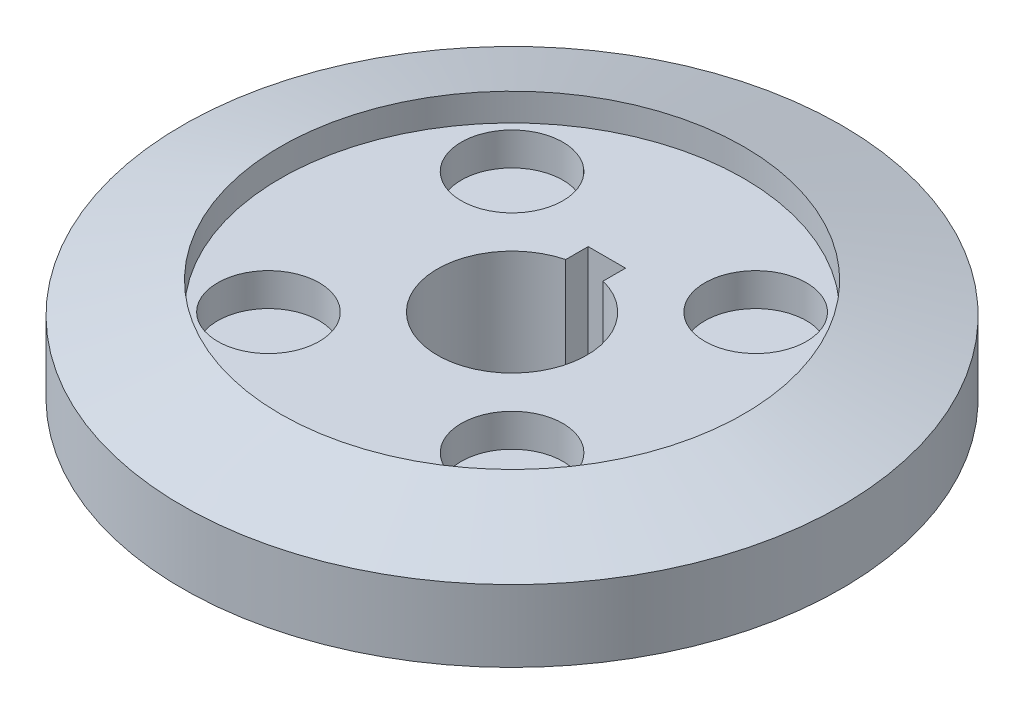
from build123d import *

# Parameters (mm, degrees)
FILLET1_R               = 1.5
CUT_EXTRUDE1_DEPTH      = 32.924764682
CUT_EXTRUDE1_DEPTH_BACK = 32.924764682
SKETCH2_W               = 2.5
SKETCH2_H               = 1.5
SKETCH3_R               = 3.4
CUT_EXTRUDE2_DEPTH      = 2.2
CIRPATTERN1_COUNT       = 4


with BuildPart() as part:
    # Sketch1 → Revolve1 (revolve)
    with BuildSketch(Plane.XY):
        Polygon((5, -6), (10.05, -6), (10.05, 0), (22.05, 0), (22.05, 4.8), (15.5, 6.84), (15.5, 5), (5, 5), align=None)
    revolve(axis=Axis((0, 0, 0), (0, 1, 0)))

    # Fillet1
    fillet1_edges = [part.edges().sort_by_distance(p)[0] for p in [
        (-10.05, 0, 0),
    ]]
    fillet(fillet1_edges, radius=FILLET1_R)

    # Sketch2 → Cut-Extrude1 (cut, two sides: drawn at the far end of the back side and taken through both)
    with BuildSketch(Plane(origin=(0, 0, 0), x_dir=(1, 0, 0), z_dir=(0, 1, 0)).offset(-CUT_EXTRUDE1_DEPTH_BACK)):
        with Locations((0, 5.591229183)):
            Rectangle(SKETCH2_W, SKETCH2_H)
    extrude(amount=CUT_EXTRUDE1_DEPTH + CUT_EXTRUDE1_DEPTH_BACK, mode=Mode.SUBTRACT)

    # Sketch3 → Cut-Extrude2 (cut)
    with BuildSketch(Plane(origin=(0, 5, 0), x_dir=(1, 0, 0), z_dir=(0, 1, 0))):
        with Locations((8.149405653, 8.149405653)):
            Circle(SKETCH3_R)
    cut_extrude2 = extrude(amount=-CUT_EXTRUDE2_DEPTH, mode=Mode.SUBTRACT)

    # CirPattern1: Cut-Extrude2 ×4 about axis
    cirpattern1_axis = Axis((0, 11.450026178, 0), (0, -1, 0))
    for i in range(1, CIRPATTERN1_COUNT):
        add(cut_extrude2.rotate(cirpattern1_axis, i * 360 / CIRPATTERN1_COUNT), mode=Mode.SUBTRACT)


solid = part.part
